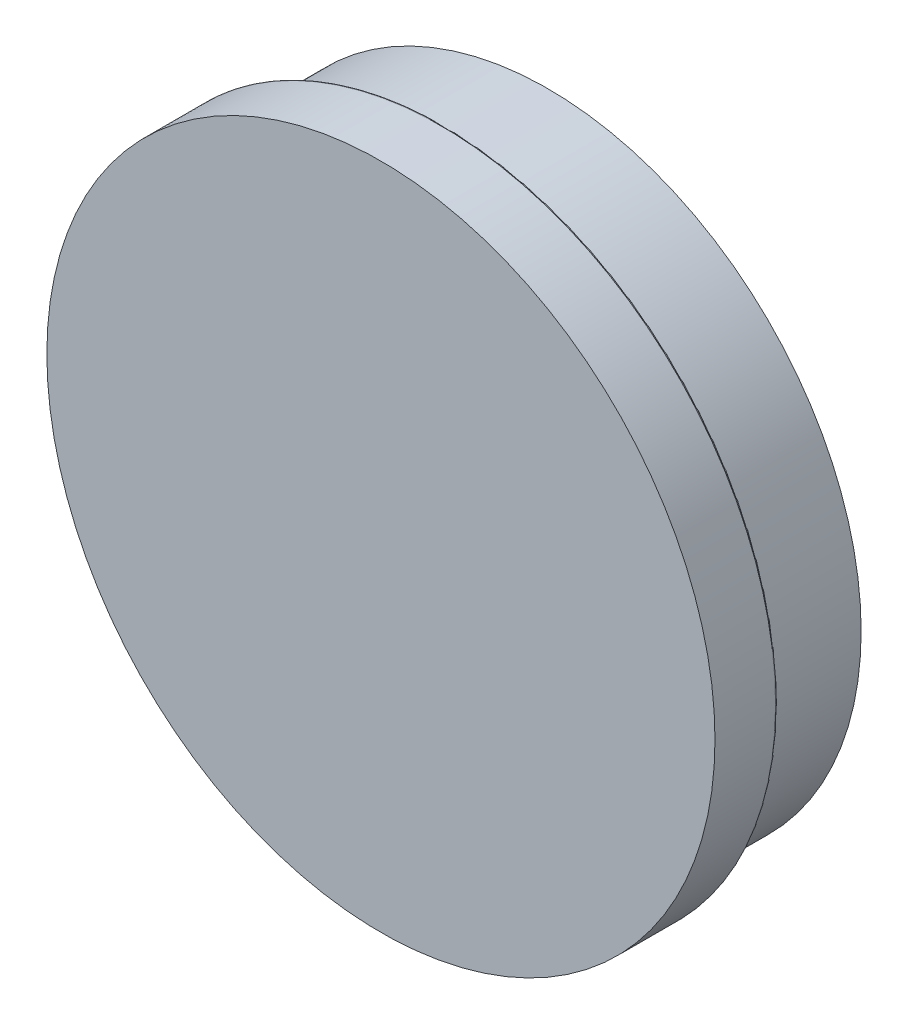
from build123d import *

# Parameters (mm, degrees)
SKETCH3_R           = 15
BOSS_EXTRUDE1_DEPTH = 5
SKETCH4_R           = 11.5
CUT_EXTRUDE1_DEPTH  = 3
FILLET1_R           = 1
FILLET2_R           = 0.2
SKETCH5_R           = 16
BOSS_EXTRUDE2_DEPTH = 3
FILLET3_R           = 0.1


with BuildPart() as part:
    # Sketch3 → Boss-Extrude1 (new body)
    with BuildSketch(Plane.XY):
        Circle(SKETCH3_R)
    extrude(amount=BOSS_EXTRUDE1_DEPTH)

    # Sketch4 → Cut-Extrude1 (cut)
    with BuildSketch(Plane(origin=(0, 0, 0), x_dir=(-1, 0, 0), z_dir=(0, 0, -1))):
        Circle(SKETCH4_R)
    extrude(amount=-CUT_EXTRUDE1_DEPTH, mode=Mode.SUBTRACT)

    # Fillet1
    fillet1_edges = [part.edges().sort_by_distance(p)[0] for p in [
        (11.5, 0, 3),
    ]]
    fillet(fillet1_edges, radius=FILLET1_R)

    # Fillet2
    fillet2_edges = [part.edges().sort_by_distance(p)[0] for p in [
        (11.5, 0, 0),
    ]]
    fillet(fillet2_edges, radius=FILLET2_R)

    # Sketch5 → Boss-Extrude2 (add)
    with BuildSketch(Plane.XY.offset(5)):
        Circle(SKETCH5_R)
    extrude(amount=BOSS_EXTRUDE2_DEPTH)

    # Fillet3
    fillet3_edges = [part.edges().sort_by_distance(p)[0] for p in [
        (-16, 0, 5),
        (-15, 0, 5),
    ]]
    fillet(fillet3_edges, radius=FILLET3_R)


solid = part.part
